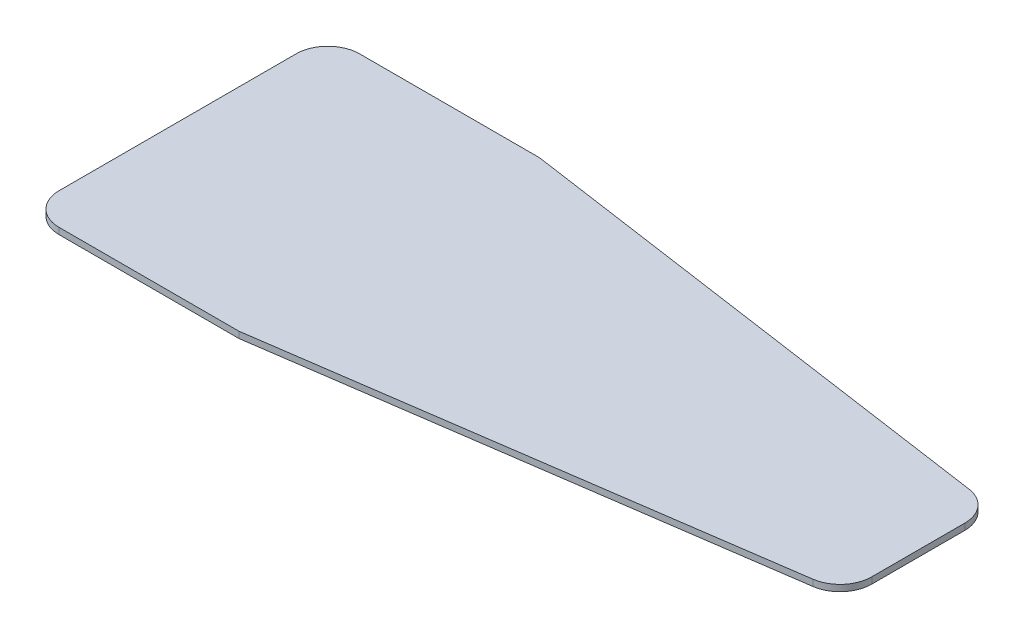
from build123d import *

# Parameters (mm, degrees)
BOSS_EXTRUDE1_DEPTH = 3


with BuildPart() as part:
    # Sketch1 → Boss-Extrude1 (new body)
    with BuildSketch(Plane(origin=(0, 0, 0), x_dir=(1, 0, 0), z_dir=(0, 1, 0))):
        with BuildLine():
            Line((15, 0), (100, 0))
            Line((100, 0), (337.137947494, 34.147864439))
            ThreePointArc((337.137947494, 34.147864439), (346.33731036, 39.173042252), (350, 48.994722036))
            Line((350, 48.994722036), (350, 93.005277964))
            ThreePointArc((350, 93.005277964), (346.33731036, 102.826957748), (337.137947494, 107.852135561))
            Line((337.137947494, 107.852135561), (100, 142))
            Line((100, 142), (15, 142))
            ThreePointArc((15, 142), (4.393398282, 137.606601718), (0, 127))
            Line((0, 127), (0, 15))
            ThreePointArc((0, 15), (4.393398282, 4.393398282), (15, 0))
        make_face()
    extrude(amount=BOSS_EXTRUDE1_DEPTH)


solid = part.part
